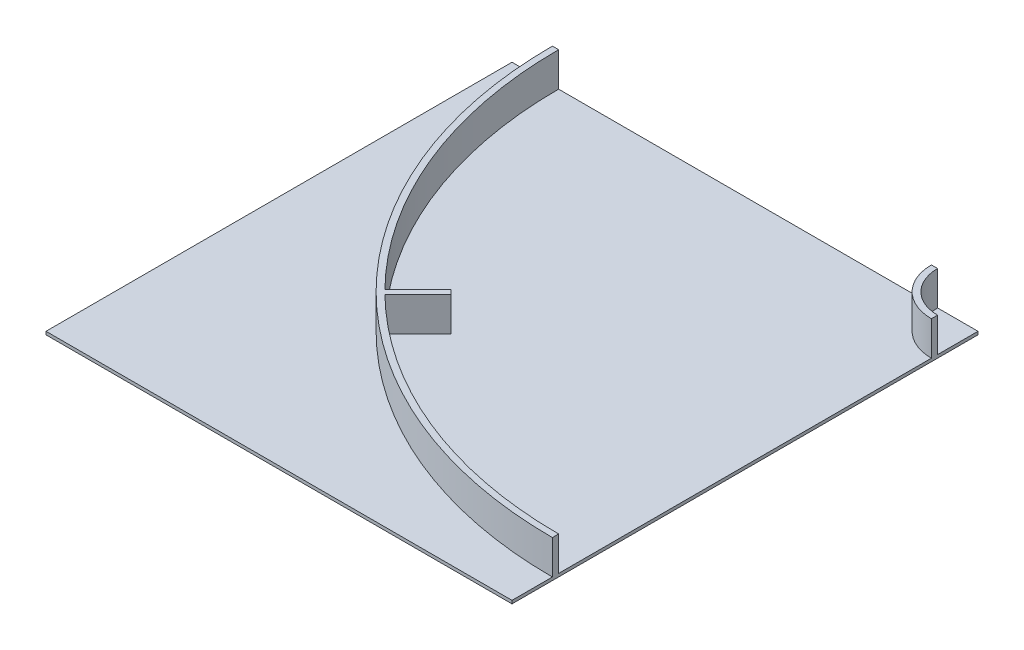
from build123d import *

# Parameters (mm, degrees)
SKETCH2_W           = 1500
SKETCH2_H           = 1500
BOSS_EXTRUDE1_DEPTH = 10
BOSS_EXTRUDE2_DEPTH = 110
BOSS_EXTRUDE3_DEPTH = 110


with BuildPart() as part:
    # Sketch2 → Boss-Extrude1 (new body)
    with BuildSketch(Plane(origin=(0, 0, 0), x_dir=(1, 0, 0), z_dir=(0, 1, 0))):
        Rectangle(SKETCH2_W, SKETCH2_H)
    extrude(amount=BOSS_EXTRUDE1_DEPTH)

    # Sketch3 → Boss-Extrude2 (add)
    with BuildSketch(Plane(origin=(0, 10, 0), x_dir=(1, 0, 0), z_dir=(0, 1, 0))):
        with BuildLine():
            ThreePointArc((750, -600), (-204.594154602, -204.594154602), (-600, 750))
            Line((-600, 750), (-620, 750))
            ThreePointArc((-620, 750), (-218.736290226, -218.736290226), (750, -620))
            Line((750, -620), (750, -600))
        make_face()
        with BuildLine():
            Line((620, 750), (600, 750))
            ThreePointArc((600, 750), (643.933982822, 643.933982822), (750, 600))
            Line((750, 600), (750, 620))
            ThreePointArc((750, 620), (658.076118446, 658.076118446), (620, 750))
        make_face()
    extrude(amount=BOSS_EXTRUDE2_DEPTH)

    # Sketch4 → Boss-Extrude3 (add)
    with BuildSketch(Plane(origin=(0, 10, 0), x_dir=(1, 0, 0), z_dir=(0, 1, 0))):
        Polygon((-197.52308679, -211.665222414), (-91.457069612, -105.599205236), (-105.599205236, -91.457069612), (-211.665222414, -197.52308679), align=None)
    extrude(amount=BOSS_EXTRUDE3_DEPTH)


solid = part.part
